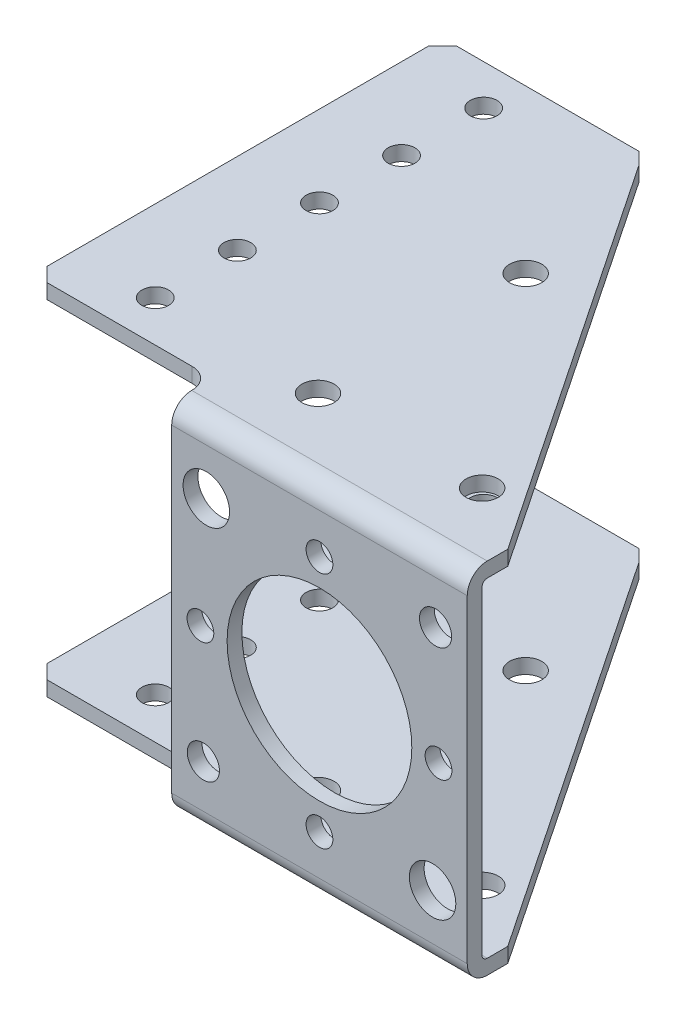
from build123d import *

# Parameters (mm, degrees)
SKETCH1_W                  = 42.545
SKETCH1_H                  = 50.927
BOSS_EXTRUDE1_DEPTH        = 6.2738
BOSS_EXTRUDE2_DEPTH        = 2.286
BOSS_EXTRUDE3_DEPTH        = 2.286
SKETCH4_W                  = 42.545
SKETCH4_H                  = 50.927
CUT_EXTRUDE1_DEPTH         = 3.9878
BOSS_EXTRUDE4_DEPTH        = 3.175
SKETCH6_W                  = 63.373
SKETCH6_H                  = 2.286
BOSS_EXTRUDE5_DEPTH        = 27.813
SKETCH7_W                  = 63.373
SKETCH7_H                  = 2.286
BOSS_EXTRUDE6_DEPTH        = 27.813
HOLE1_D                    = 4.9784
HOLE1_DEPTH                = 2.286
M3_5_CLEARANCE_HOLE1_D     = 4.1402
M3_5_CLEARANCE_HOLE1_DEPTH = 2.286
M25_CLEARANCE_HOLE1_D      = 28.575
M25_CLEARANCE_HOLE1_DEPTH  = 2.286025
HOLE2_D                    = 4.9784
HOLE2_DEPTH                = 2.286025
M6_5_CLEARANCE_HOLE1_D     = 7.1882
M6_5_CLEARANCE_HOLE1_DEPTH = 2.286025
M3_5_CLEARANCE_HOLE2_D     = 4.1402
M3_5_CLEARANCE_HOLE2_DEPTH = 2.286025
HOLE3_D                    = 4.9784
HOLE3_DEPTH                = 55.499
M3_5_CLEARANCE_HOLE3_D     = 4.1402
M3_5_CLEARANCE_HOLE3_DEPTH = 55.499
CHAMFER1_SIZE              = 2.159
CHAMFER1_SIZE2             = 0.59078994
CHAMFER2_SIZE              = 2.159
CHAMFER3_SIZE2             = 0.59078994
CHAMFER3_SIZE              = 2.159
FILLET1_R                  = 0.8128
FILLET2_R                  = 3.0988
FILLET3_R                  = 3.2004


with BuildPart() as part:
    # Sketch1 → Boss-Extrude1 (new body)
    with BuildSketch(Plane.XY.offset(2.286)):
        with Locations((1.5875, 0)):
            Rectangle(SKETCH1_W, SKETCH1_H)
    extrude(amount=-BOSS_EXTRUDE1_DEPTH)

    # Sketch2 → Boss-Extrude2 (add)
    with BuildSketch(Plane.XZ.offset(25.4635)):
        Polygon((-19.685, 2.286), (22.86, 2.286), (22.86, -3.9878), (-19.685, -67.437), align=None)
    extrude(amount=BOSS_EXTRUDE2_DEPTH)

    # Sketch3 → Boss-Extrude3 (add)
    with BuildSketch(Plane(origin=(0, 25.4635, 0), x_dir=(-1, 0, 0), z_dir=(0, 1, 0))):
        Polygon((19.685, -67.437), (-22.86, -3.9878), (-22.86, 2.286), (19.685, 2.286), align=None)
    extrude(amount=BOSS_EXTRUDE3_DEPTH)

    # Sketch4 → Cut-Extrude1 (cut)
    with BuildSketch(Plane(origin=(0, 0, -3.9878), x_dir=(-1, 0, 0), z_dir=(0, 0, -1))):
        with Locations((-1.5875, 0)):
            Rectangle(SKETCH4_W, SKETCH4_H)
    extrude(amount=-CUT_EXTRUDE1_DEPTH, mode=Mode.SUBTRACT)

    # Sketch5 → Boss-Extrude4 (add)
    with BuildSketch(Plane.ZY.offset(19.685)):
        Polygon((0, -25.4635), (0, 25.4635), (-67.437, 25.4635), (-67.437, 27.7495), (2.286, 27.7495), (2.286, -27.7495), (-67.437, -27.7495), (-67.437, -25.4635), align=None)
    extrude(amount=BOSS_EXTRUDE4_DEPTH)

    # Sketch6 → Boss-Extrude5 (add)
    with BuildSketch(Plane.ZY.offset(22.86)):
        with Locations((-35.7505, 26.6065)):
            Rectangle(SKETCH6_W, SKETCH6_H)
    extrude(amount=BOSS_EXTRUDE5_DEPTH)

    # Sketch7 → Boss-Extrude6 (add)
    with BuildSketch(Plane.ZY.offset(22.86)):
        with Locations((-35.7505, -26.6065)):
            Rectangle(SKETCH7_W, SKETCH7_H)
    extrude(amount=BOSS_EXTRUDE6_DEPTH)

    # Hole1
    with Locations(Plane(origin=(0, -25.4635, 0), x_dir=(1, 0, 0), z_dir=(0, 1, 0))):
        with Locations((-12.7, 10.1854), (12.7, 10.1854), (-12.7, 42.3164)):
            Hole(HOLE1_D / 2, depth=HOLE1_DEPTH)

    # M3.5 Clearance Hole1
    with Locations(Plane(origin=(0, -25.4635, 0), x_dir=(1, 0, 0), z_dir=(0, 1, 0))):
        with Locations((-38.1, 61.214), (-38.1, 48.514), (-38.1, 35.814), (-38.1, 23.114), (-38.1, 10.414)):
            Hole(M3_5_CLEARANCE_HOLE1_D / 2, depth=M3_5_CLEARANCE_HOLE1_DEPTH)

    # M25 Clearance Hole1
    with Locations(Plane(origin=(0, 0, 0), x_dir=(-1, 0, 0), z_dir=(0, 0, -1))):
        with Locations((0, 0)):
            Hole(M25_CLEARANCE_HOLE1_D / 2, depth=M25_CLEARANCE_HOLE1_DEPTH)

    # Hole2
    with Locations(Plane(origin=(0, 0, 0), x_dir=(-1, 0, 0), z_dir=(0, 0, -1))):
        with Locations((-17.960512242, 17.960512242), (17.960512242, -17.960512242)):
            Hole(HOLE2_D / 2, depth=HOLE2_DEPTH)

    # M6.5 Clearance Hole1
    with Locations(Plane(origin=(0, 0, 0), x_dir=(-1, 0, 0), z_dir=(0, 0, -1))):
        with Locations((17.5, 17.5), (-17.5, -17.5)):
            Hole(M6_5_CLEARANCE_HOLE1_D / 2, depth=M6_5_CLEARANCE_HOLE1_DEPTH)

    # M3.5 Clearance Hole2
    with Locations(Plane(origin=(0, 0, 0), x_dir=(-1, 0, 0), z_dir=(0, 0, -1))):
        with Locations((18.415, 0), (0, 18.415), (0, -18.415), (-18.415, 0)):
            Hole(M3_5_CLEARANCE_HOLE2_D / 2, depth=M3_5_CLEARANCE_HOLE2_DEPTH)

    # Hole3
    with Locations(Plane(origin=(0, 27.7495, 0), x_dir=(1, 0, 0), z_dir=(0, 1, 0))):
        with Locations((-12.7, 10.1854), (12.7, 10.1854), (-12.7, 42.3164)):
            Hole(HOLE3_D / 2, depth=HOLE3_DEPTH)

    # M3.5 Clearance Hole3
    with Locations(Plane(origin=(0, 27.7495, 0), x_dir=(1, 0, 0), z_dir=(0, 1, 0))):
        with Locations((-38.1, 61.214), (-38.1, 48.514), (-38.1, 35.814), (-38.1, 23.114), (-38.1, 10.414)):
            Hole(M3_5_CLEARANCE_HOLE3_D / 2, depth=M3_5_CLEARANCE_HOLE3_DEPTH)

    # Chamfer1
    chamfer1_edges = [part.edges().sort_by_distance(p)[0] for p in [
        (-19.685, -26.6065, -67.437),
    ]]
    chamfer1_side = [part.faces().sort_by_distance(p)[0] for p in [
        (1.5875, -26.6065, -35.7124),
    ]]
    chamfer(chamfer1_edges, length=CHAMFER1_SIZE, length2=CHAMFER1_SIZE2, reference=chamfer1_side[0])

    # Chamfer2
    chamfer2_edges = [part.edges().sort_by_distance(p)[0] for p in [
        (-50.673, -26.6065, -67.437),
        (-50.673, 26.6065, -67.437),
        (-50.673, -26.6065, -4.064),
        (-50.673, 26.6065, -4.064),
    ]]
    chamfer(chamfer2_edges, length=CHAMFER2_SIZE)

    # Chamfer3
    chamfer3_edges = [part.edges().sort_by_distance(p)[0] for p in [
        (-19.685, 26.6065, -67.437),
    ]]
    chamfer(chamfer3_edges, length=CHAMFER3_SIZE, length2=CHAMFER3_SIZE2)

    # Fillet1
    fillet1_edges = [part.edges().sort_by_distance(p)[0] for p in [
        (0, 25.4635, 0),
        (0, -25.4635, 0),
    ]]
    fillet(fillet1_edges, radius=FILLET1_R)

    # Fillet2
    fillet2_edges = [part.edges().sort_by_distance(p)[0] for p in [
        (0, 27.7495, 2.286),
        (0, -27.7495, 2.286),
    ]]
    fillet(fillet2_edges, radius=FILLET2_R)

    # Fillet3
    fillet3_edges = [part.edges().sort_by_distance(p)[0] for p in [
        (-22.86, 26.6065, -4.064),
        (-22.86, -26.6065, -4.064),
    ]]
    fillet(fillet3_edges, radius=FILLET3_R)


solid = part.part
